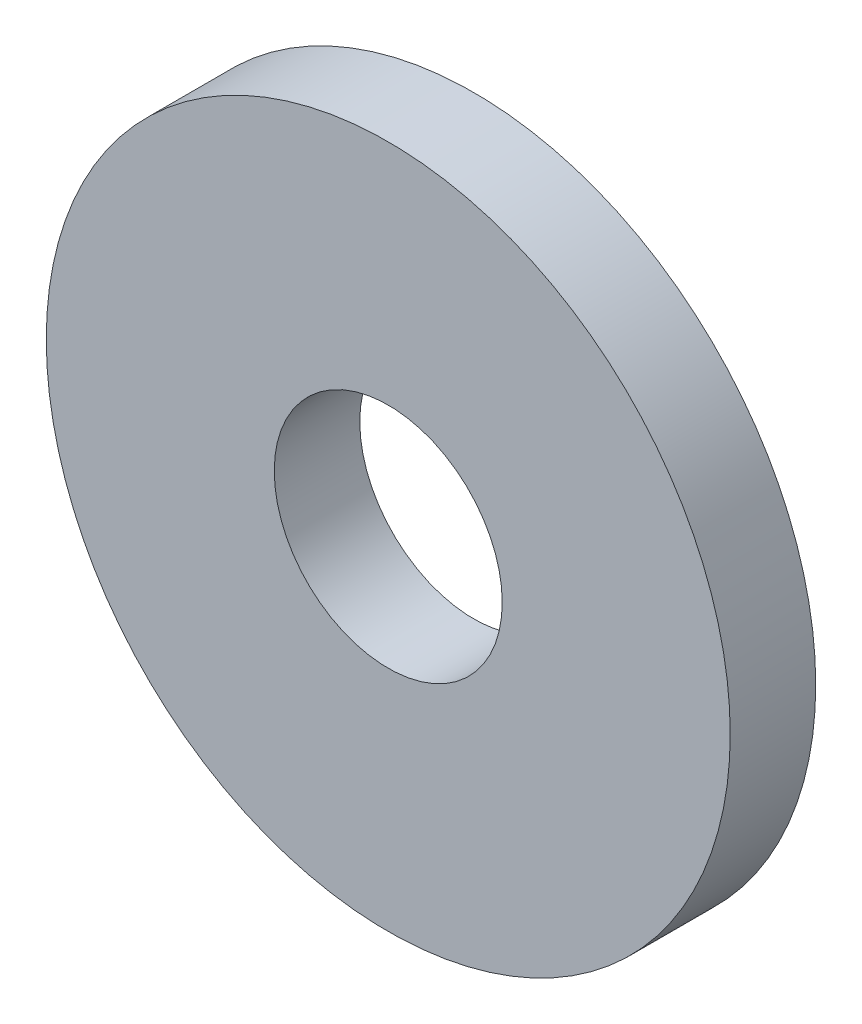
from build123d import *

# Parameters (mm, degrees)
ESBO_O1_R                = 6
ESBO_O1_R_2              = 2
RESSALTO_EXTRUS_O1_DEPTH = 1.5


with BuildPart() as part:
    # Esboço1 → Ressalto-extrusão1 (new body)
    with BuildSketch(Plane.XY):
        Circle(ESBO_O1_R)
        Circle(ESBO_O1_R_2, mode=Mode.SUBTRACT)
    extrude(amount=RESSALTO_EXTRUS_O1_DEPTH)


solid = part.part
